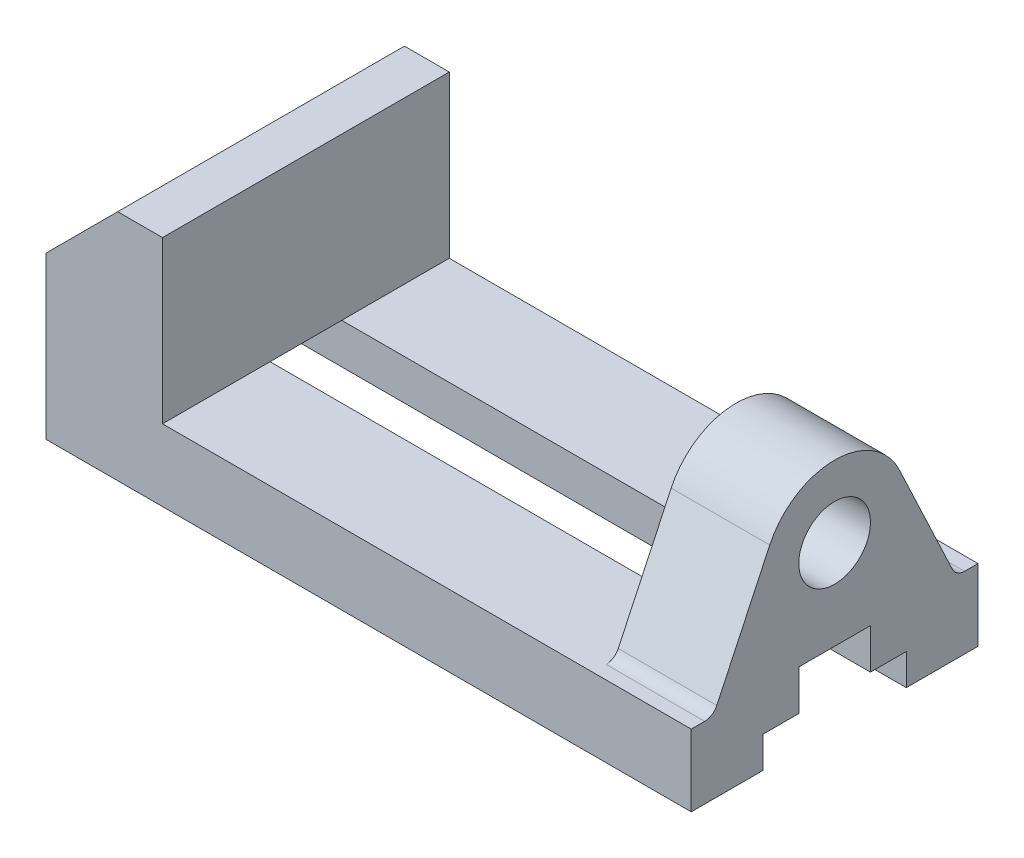
from build123d import *

# Parameters (mm, degrees)
BOSS_EXTRUDE1_DEPTH = 32
CUT_EXTRUDE1_REACH  = 146
SKETCH4_R           = 8
BOSS_EXTRUDE3_DEPTH = 22


with BuildPart() as part:
    # Sketch1 → Boss-Extrude1 (new body, symmetric)
    with BuildSketch(Plane.XY):
        Polygon((-72, 8), (-72, 28), (-56, 44), (-46, 44), (-46, 8), (72, 8), (72, -8), (-72, -8), align=None)
    extrude(amount=BOSS_EXTRUDE1_DEPTH, both=True)

    # Sketch2 → Cut-Extrude1 (cut, up to next)
    with BuildSketch(Plane(origin=(72, 0, 0), x_dir=(0, 0, -1), z_dir=(1, 0, 0)), mode=Mode.PRIVATE) as cut_extrude1_sk1:
        Polygon((-16, -8), (-16, -1), (-8, -1), (-8, 8), (8, 8), (8, -1), (16, -1), (16, -8), align=None)
    cut_extrude1_tool1 = extrude(cut_extrude1_sk1.sketch, amount=-CUT_EXTRUDE1_REACH, mode=Mode.PRIVATE) & part.part
    add(cut_extrude1_tool1.solids().sort_by_distance((72, -1.369565, 0))[0], mode=Mode.SUBTRACT)

    # Sketch4 → Boss-Extrude3 (add)
    with BuildSketch(Plane(origin=(72, 0, 0), x_dir=(0, 0, -1), z_dir=(1, 0, 0))):
        with BuildLine():
            Line((-14.476806191, 34.813375266), (-26.285598839, 9.722492138))
            ThreePointArc((-26.285598839, 9.722492138), (-27.392598928, 8.466965892), (-29, 8))
            Line((-29, 8), (29, 8))
            ThreePointArc((29, 8), (27.392598928, 8.466965892), (26.285598839, 9.722492138))
            Line((26.285598839, 9.722492138), (14.476806191, 34.813375266))
            ThreePointArc((14.476806191, 34.813375266), (0, 44), (-14.476806191, 34.813375266))
        make_face()
        with Locations((0, 28)):
            Circle(SKETCH4_R, mode=Mode.SUBTRACT)
    extrude(amount=-BOSS_EXTRUDE3_DEPTH)


solid = part.part
